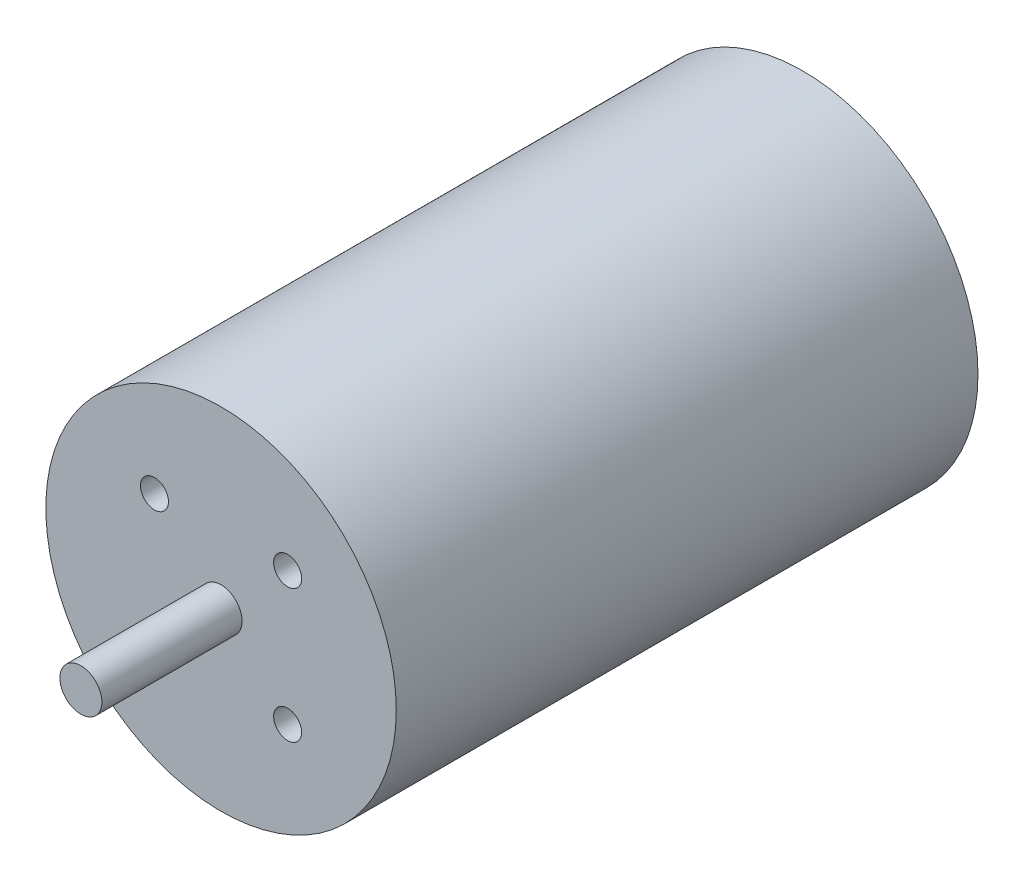
from build123d import *

# Parameters (mm, degrees)
SKETCH1_R           = 25
BOSS_EXTRUDE1_DEPTH = 83
SKETCH2_R           = 3
BOSS_EXTRUDE2_DEPTH = 20
SKETCH3_R           = 2
CUT_EXTRUDE1_DEPTH  = 10


with BuildPart() as part:
    # Sketch1 → Boss-Extrude1 (new body)
    with BuildSketch(Plane.XY):
        Circle(SKETCH1_R)
    extrude(amount=BOSS_EXTRUDE1_DEPTH)

    # Sketch2 → Boss-Extrude2 (add)
    with BuildSketch(Plane.XY.offset(83)):
        Circle(SKETCH2_R)
    extrude(amount=BOSS_EXTRUDE2_DEPTH)

    # Sketch3 → Cut-Extrude1 (cut)
    with BuildSketch(Plane.XY.offset(83)):
        with Locations((-9.5, 9.5)):
            Circle(SKETCH3_R)
        with Locations((-9.5, -9.5)):
            Circle(SKETCH3_R)
        with Locations((9.5, -9.5)):
            Circle(SKETCH3_R)
        with Locations((9.5, 9.5)):
            Circle(SKETCH3_R)
    extrude(amount=-CUT_EXTRUDE1_DEPTH, mode=Mode.SUBTRACT)


solid = part.part
